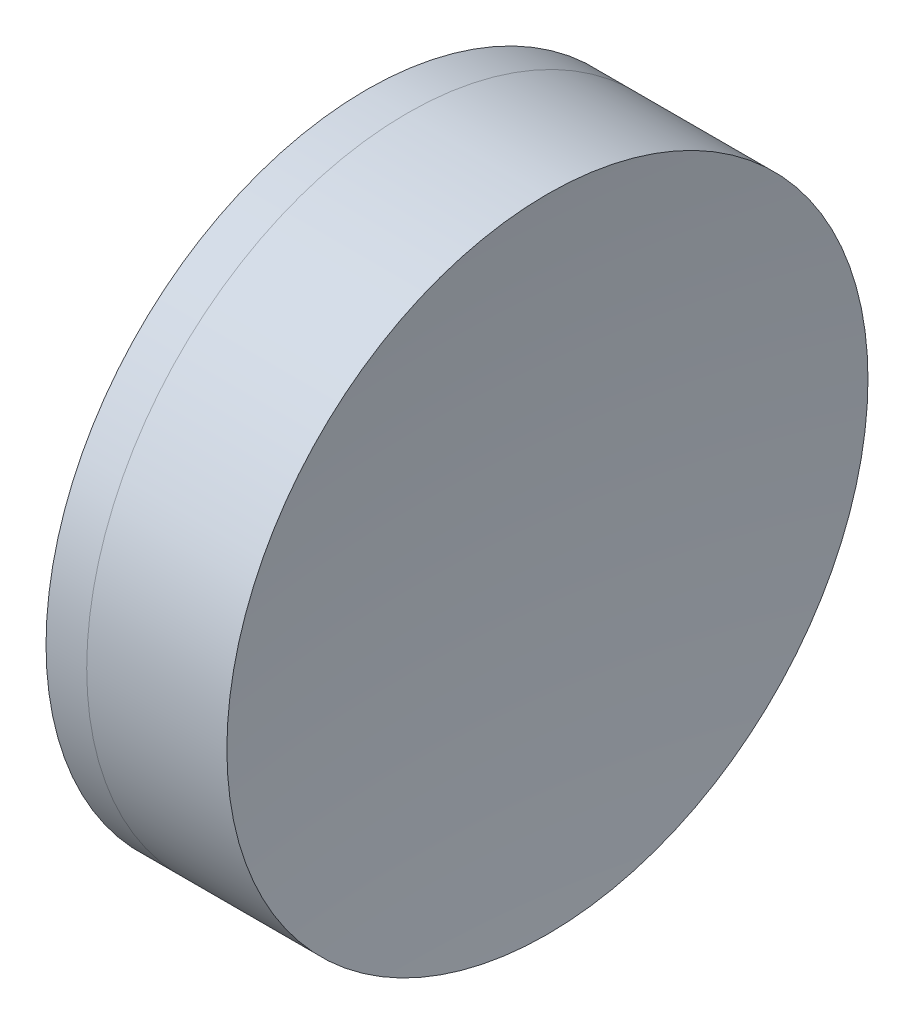
from build123d import *


with BuildPart() as part:
    # 草图1 one side → 旋转1 (revolve)
    with BuildSketch(Plane(origin=(0, 0, 0), x_dir=(1, 0, 0), z_dir=(0, 1, 0)), mode=Mode.PRIVATE) as revolve_1_sk:
        with BuildLine():
            ThreePointArc((36.863750972, 12.7), (34.139108527, 6.608037013), (33.206619216, 0))
            Line((33.206619216, 0), (41.506619216, 0))
            ThreePointArc((41.506619216, 0), (40.738305661, 6.528372587), (38.475349754, 12.7))
            Line((38.475349754, 12.7), (36.863750972, 12.7))
        make_face()
    revolve(revolve_1_sk.sketch.rotate(Axis((-0.816062176, 0, 0), (1, 0, 0)), 180), axis=Axis((-0.816062176, 0, 0), (1, 0, 0)))  # turned: the seam where the file's is


with BuildPart() as body_2:
    # 草图2 one side → 旋转2 (revolve)
    with BuildSketch(Plane(origin=(0, 0, 0), x_dir=(1, 0, 0), z_dir=(0, 1, 0)), mode=Mode.PRIVATE) as revolve_2_sk:
        with BuildLine():
            Line((44.028474476, 12.7), (38.475349754, 12.7))
            ThreePointArc((38.475349754, 12.7), (40.738305661, 6.528372587), (41.506619216, 0))
            Line((41.506619216, 0), (43.306619216, 0))
            ThreePointArc((43.306619216, 0), (43.487228551, 6.360249111), (44.028474476, 12.7))
        make_face()
    revolve(revolve_2_sk.sketch.rotate(Axis((-0.551919993, 0, 0), (1, 0, 0)), 180), axis=Axis((-0.551919993, 0, 0), (1, 0, 0)))  # turned: the seam where the file's is


solid = Compound([part.part, body_2.part])
